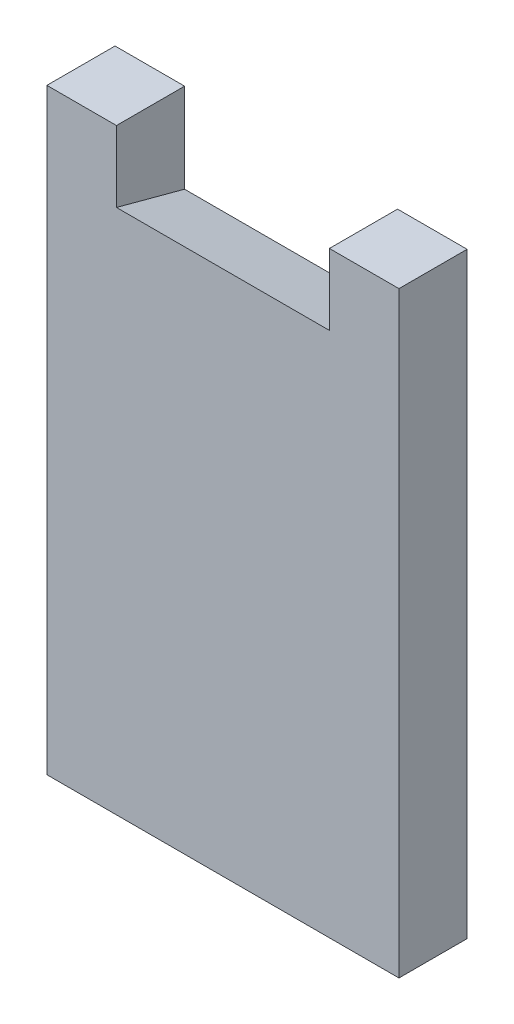
from build123d import *

# Parameters (mm, degrees)
EXTRUDE_1_DEPTH = 9.6
DRAFT_5_ANGLE   = -15


with BuildPart() as part:
    # 草图1 → 凸台-拉伸1 (new body)
    with BuildSketch(Plane.XY):
        Polygon((9.8, 0), (0, 0), (0, -84.11), (49.6, -84.11), (49.6, 0), (39.8, 0), (39.8, -10), (9.8, -10), align=None)
    extrude(amount=EXTRUDE_1_DEPTH)

    # 拔模5
    draft_5_faces = [part.faces().sort_by_distance(p)[0] for p in [
        (24.8, -10, 4.8),
    ]]
    draft(draft_5_faces, Plane.XY.offset(9.6), DRAFT_5_ANGLE)


solid = part.part
